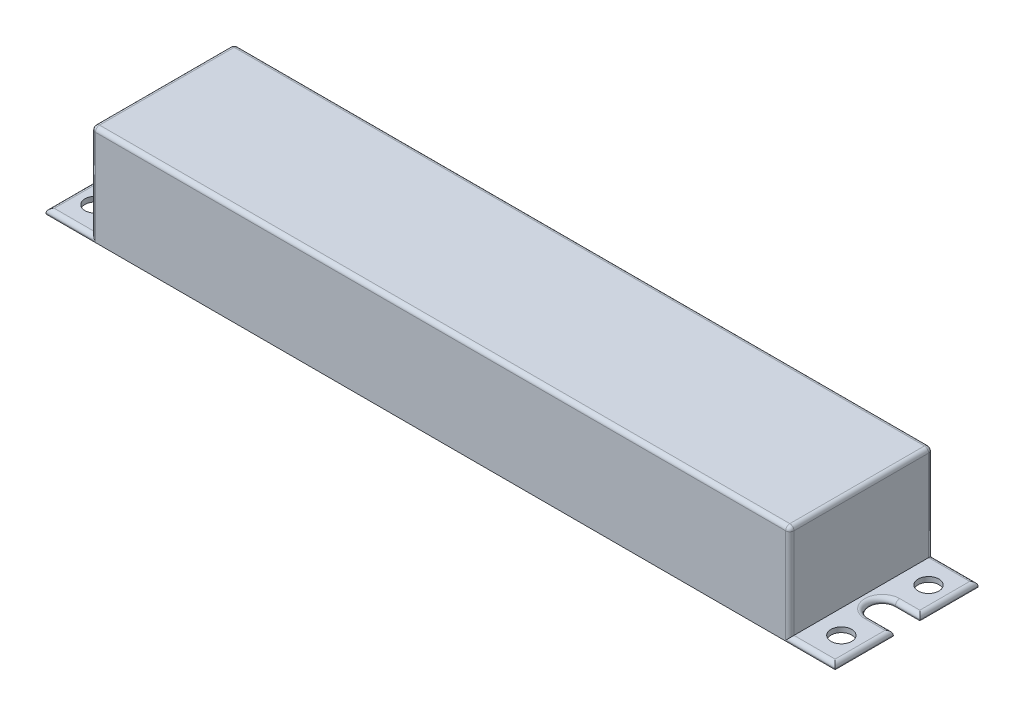
from build123d import *

# Parameters (mm, degrees)
SKETCH1_W                   = 241.3
SKETCH1_H                   = 43.688
BOSS_EXTRUDE1_DEPTH         = 1.524
F_1_4_0_25_DIAMETER_HOLE1_D = 6.35
CUT_EXTRUDE1_DEPTH          = 2.524
SKETCH5_W                   = 213.614
SKETCH5_H                   = 43.688
BOSS_EXTRUDE2_DEPTH         = 28.956
FILLET2_R                   = 1.27


with BuildPart() as part:
    # Sketch1 → Boss-Extrude1 (new body)
    with BuildSketch(Plane(origin=(0, 0, 0), x_dir=(1, 0, 0), z_dir=(0, 1, 0))):
        Rectangle(SKETCH1_W, SKETCH1_H)
    extrude(amount=BOSS_EXTRUDE1_DEPTH)

    # 1/4 (0.25) Diameter Hole1 (through all)
    with Locations(Plane(origin=(0, 1.524, 0), x_dir=(1, 0, 0), z_dir=(0, 1, 0))):
        with Locations((114.046, -13.335), (-114.046, 13.335), (-114.046, -13.335), (114.046, 13.335)):
            Hole(F_1_4_0_25_DIAMETER_HOLE1_D / 2)

    # Sketch4 → Cut-Extrude1 (cut, through all)
    with BuildSketch(Plane(origin=(0, 1.524, 0), x_dir=(1, 0, 0), z_dir=(0, 1, 0))):
        with BuildLine():
            Line((-120.65, 4.064), (-113.2205, 4.064))
            ThreePointArc((-113.2205, 4.064), (-109.1565, 0), (-113.2205, -4.064))
            Line((-113.2205, -4.064), (-120.65, -4.064))
            Line((-120.65, -4.064), (-120.65, 4.064))
        make_face()
        with BuildLine():
            Line((113.2205, 4.064), (120.65, 4.064))
            Line((120.65, 4.064), (120.65, -4.064))
            Line((120.65, -4.064), (113.2205, -4.064))
            ThreePointArc((113.2205, -4.064), (109.1565, 0), (113.2205, 4.064))
        make_face()
    extrude(amount=-CUT_EXTRUDE1_DEPTH, mode=Mode.SUBTRACT)

    # Sketch5 → Boss-Extrude2 (add)
    with BuildSketch(Plane(origin=(0, 1.524, 0), x_dir=(1, 0, 0), z_dir=(0, 1, 0))):
        Rectangle(SKETCH5_W, SKETCH5_H)
    extrude(amount=BOSS_EXTRUDE2_DEPTH)

    # Fillet2
    fillet2_edges = [part.edges().sort_by_distance(p)[0] for p in [
        (-120.65, 1.524, -12.954),
        (-113.7285, 1.524, 21.844),
        (120.65, 1.524, -12.954),
        (120.65, 1.524, 12.954),
        (116.93525, 1.524, -4.064),
        (109.1565, 1.524, 0),
        (116.93525, 1.524, 4.064),
        (-120.65, 1.524, 12.954),
        (-109.1565, 1.524, 0),
        (-116.93525, 1.524, -4.064),
        (-116.93525, 1.524, 4.064),
        (113.7285, 1.524, 21.844),
        (-113.7285, 1.524, -21.844),
        (106.807, 16.002, 21.844),
        (106.807, 16.002, -21.844),
        (-106.807, 16.002, -21.844),
        (-106.807, 16.002, 21.844),
        (106.807, 30.48, 0),
        (113.7285, 1.524, -21.844),
        (0, 30.48, -21.844),
        (-106.807, 30.48, 0),
        (0, 30.48, 21.844),
    ]]
    fillet(fillet2_edges, radius=FILLET2_R)


solid = part.part
